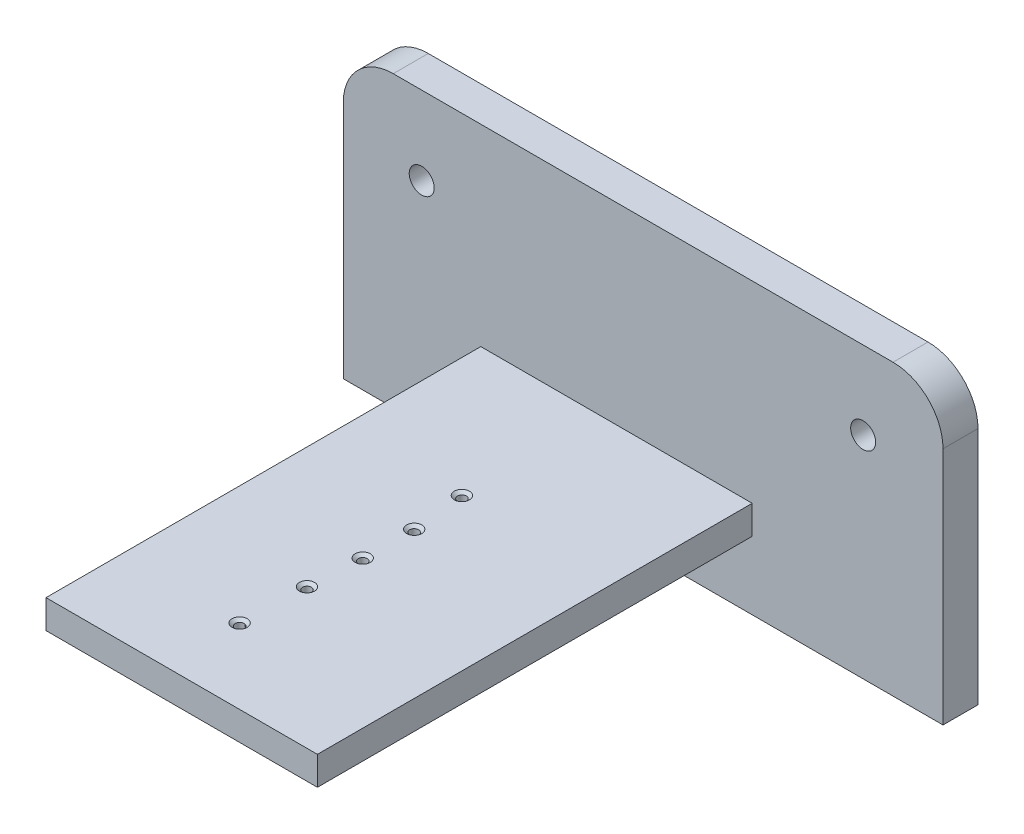
from build123d import *

# Parameters (mm, degrees)
SKETCH1_W                                         = 120
SKETCH1_H                                         = 57.864768683
SKETCH1_R                                         = 2.5
BOSS_EXTRUDE1_DEPTH                               = 7
SKETCH2_W                                         = 54.306051878
SKETCH2_H                                         = 5.719890942
BOSS_EXTRUDE2_DEPTH                               = 87
FILLET1_R                                         = 10
CSK_FOR_0_FLAT_HEAD_MACHINE_SCREW_100_D           = 1.778
CSK_FOR_0_FLAT_HEAD_MACHINE_SCREW_100_CSINK_D     = 3.0226
CSK_FOR_0_FLAT_HEAD_MACHINE_SCREW_100_CSINK_ANGLE = 100


with BuildPart() as part:
    # Sketch1 → Boss-Extrude1 (new body)
    with BuildSketch(Plane.XY):
        with Locations((-0.106761566, 0.160142349)):
            Rectangle(SKETCH1_W, SKETCH1_H)
        with Locations((-44.412811388, 13.398576512)):
            Circle(SKETCH1_R, mode=Mode.SUBTRACT)
        with Locations((43.912956959, 13.468374771)):
            Circle(SKETCH1_R, mode=Mode.SUBTRACT)
    extrude(amount=BOSS_EXTRUDE1_DEPTH)

    # Sketch2 → Boss-Extrude2 (add)
    with BuildSketch(Plane.XY.offset(7)):
        with Locations((-5.436912955, -12.302569894)):
            Rectangle(SKETCH2_W, SKETCH2_H)
    extrude(amount=BOSS_EXTRUDE2_DEPTH)

    # Fillet1
    fillet1_edges = [part.edges().sort_by_distance(p)[0] for p in [
        (-60.106761566, 29.09252669, 3.5),
        (59.893238434, 29.09252669, 3.5),
    ]]
    fillet(fillet1_edges, radius=FILLET1_R)

    # CSK for #0 Flat Head Machine Screw (100)1 (through all)
    with Locations(Plane(origin=(0, -9.442624423, 0), x_dir=(1, 0, 0), z_dir=(0, 1, 0))):
        with Locations((-8.675393381, -34.699580631), (-7.599346026, -45.314885455), (-7.757212548, -55.462997779), (-8.364022161, -66.007770116), (-8.816821696, -79.027415228)):
            CounterSinkHole(CSK_FOR_0_FLAT_HEAD_MACHINE_SCREW_100_D / 2, CSK_FOR_0_FLAT_HEAD_MACHINE_SCREW_100_CSINK_D / 2, counter_sink_angle=CSK_FOR_0_FLAT_HEAD_MACHINE_SCREW_100_CSINK_ANGLE)


solid = part.part
